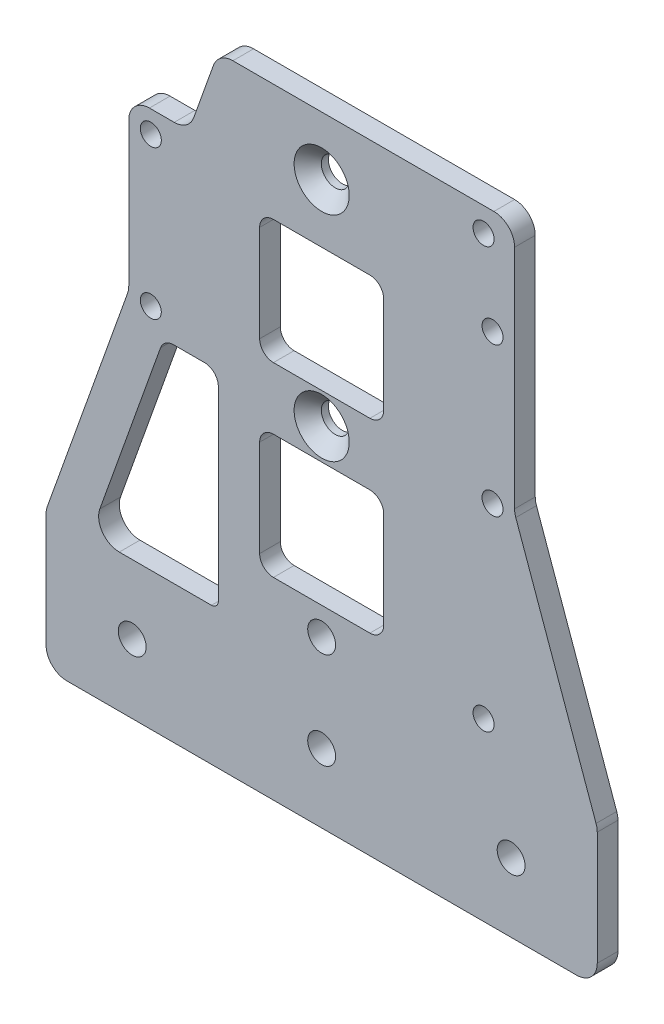
from build123d import *

# Parameters (mm, degrees)
EXTRUDE_1_DEPTH           = 1.5
SKETCH_2_W                = 18
SKETCH_2_H                = 18
CUT_EXTRUDE_1_DEPTH       = 3
FILLET_1_R                = 1
FILLET_2_R                = 2
FILLET_3_R                = 3
SKETCH_3_R                = 2.025
CUT_EXTRUDE_2_DEPTH       = 1
CUT_EXTRUDE_2_DEPTH_BACK  = 4
SKETCH_4_R                = 2.025
CUT_EXTRUDE_3_DEPTH       = 1
CUT_EXTRUDE_3_DEPTH_BACK  = 4
SKETCH_5_R                = 2.025
CUT_EXTRUDE_4_DEPTH       = 1
CUT_EXTRUDE_4_DEPTH_BACK  = 4
FILLET_4_R                = 3
EXTRUDE_2_DEPTH           = 3
FILLET_5_R                = 3
SKETCH_7_R                = 1.525
CUT_EXTRUDE_5_DEPTH       = 3
HOLE_WIZARD_1_D           = 4.05
HOLE_WIZARD_1_DEPTH       = 100
HOLE_WIZARD_1_CSINK_D     = 8
HOLE_WIZARD_1_CSINK_ANGLE = 90
EXTRUDE_3_DEPTH           = 3
FILLET_6_R                = 3
SKETCH_12_R               = 1.525
CUT_EXTRUDE_6_DEPTH       = 1
CUT_EXTRUDE_6_DEPTH_BACK  = 4
FILLET_7_R                = 2


with BuildPart() as part:
    # 草图1 → 凸台-拉伸1 (new body, symmetric)
    with BuildSketch(Plane.XY):
        Polygon((40, 0), (-40, 0), (-40, 20), (-15, 90), (15, 90), (40, 20), align=None)
    extrude(amount=EXTRUDE_1_DEPTH, both=True)

    # 草图2 → 切除-拉伸1 (cut)
    with BuildSketch(Plane.XY.offset(1.5)):
        Polygon((-15, 72.160717503), (-33.62882768, 20), (-15, 20), align=None)
        with Locations((0, 64)):
            Rectangle(SKETCH_2_W, SKETCH_2_H)
        with Locations((0, 37)):
            Rectangle(SKETCH_2_W, SKETCH_2_H)
    extrude(amount=-CUT_EXTRUDE_1_DEPTH, mode=Mode.SUBTRACT)

    # 圆角1
    fillet_1_edges = [part.edges().sort_by_distance(p)[0] for p in [
        (-15, 20, 0),
        (-15, 72.160717503, 0),
    ]]
    fillet(fillet_1_edges, radius=FILLET_1_R)

    # 圆角2
    fillet_2_edges = [part.edges().sort_by_distance(p)[0] for p in [
        (-9, 46, 0),
        (-9, 28, 0),
        (9, 28, 0),
        (9, 46, 0),
        (-9, 73, 0),
        (-9, 55, 0),
        (9, 55, 0),
        (9, 73, 0),
    ]]
    fillet(fillet_2_edges, radius=FILLET_2_R)

    # 圆角3
    fillet_3_edges = [part.edges().sort_by_distance(p)[0] for p in [
        (40, 0, 0),
        (-40, 0, 0),
        (-40, 20, 0),
        (-15, 90, 0),
        (15, 90, 0),
        (40, 20, 0),
    ]]
    fillet(fillet_3_edges, radius=FILLET_3_R)

    # 草图3 → 切除-拉伸2 (cut, two sides)
    with BuildSketch(Plane.XY.offset(1.5)) as cut_extrude_2_sk:
        with Locations((-27.5, 10)):
            Circle(SKETCH_3_R)
        with Locations((27.5, 10)):
            Circle(SKETCH_3_R)
    extrude(amount=CUT_EXTRUDE_2_DEPTH, mode=Mode.SUBTRACT)
    extrude(cut_extrude_2_sk.sketch, amount=-CUT_EXTRUDE_2_DEPTH_BACK, mode=Mode.SUBTRACT)

    # 草图4 → 切除-拉伸3 (cut, two sides)
    with BuildSketch(Plane.XY.offset(1.5)) as cut_extrude_3_sk:
        with Locations((0, 10)):
            Circle(SKETCH_4_R)
    extrude(amount=CUT_EXTRUDE_3_DEPTH, mode=Mode.SUBTRACT)
    extrude(cut_extrude_3_sk.sketch, amount=-CUT_EXTRUDE_3_DEPTH_BACK, mode=Mode.SUBTRACT)

    # 草图5 → 切除-拉伸4 (cut, two sides)
    with BuildSketch(Plane.XY.offset(1.5)) as cut_extrude_4_sk:
        with Locations((0, 24)):
            Circle(SKETCH_5_R)
        with Locations((0, 50.5)):
            Circle(SKETCH_5_R)
        with Locations((0, 81.5)):
            Circle(SKETCH_5_R)
    extrude(amount=CUT_EXTRUDE_4_DEPTH, mode=Mode.SUBTRACT)
    extrude(cut_extrude_4_sk.sketch, amount=-CUT_EXTRUDE_4_DEPTH_BACK, mode=Mode.SUBTRACT)

    # 圆角4
    fillet_4_edges = [part.edges().sort_by_distance(p)[0] for p in [
        (-33.62882768, 20, 0),
    ]]
    fillet(fillet_4_edges, radius=FILLET_4_R)

    # 草图6 → 凸台-拉伸2 (add)
    with BuildSketch(Plane(origin=(0, 0, -1.5), x_dir=(-1, 0, 0), z_dir=(0, 0, -1))):
        with BuildLine():
            Line((15, 66.387503754), (15, 50))
            Line((15, 50), (22.914541965, 50))
            Line((22.914541965, 50), (16.941741912, 66.723840151))
            ThreePointArc((16.941741912, 66.723840151), (15.82932767, 67.372831596), (15, 66.387503754))
        make_face()
        Polygon((-28, 78), (-28, 53.6), (-19.285714286, 78), align=None)
        Polygon((28, 78), (19.285714286, 78), (28, 53.6), align=None)
    extrude(amount=-EXTRUDE_2_DEPTH)

    # 圆角5
    fillet_5_edges = [part.edges().sort_by_distance(p)[0] for p in [
        (28, 53.6, 0),
        (-28, 78, 0),
        (19.285714286, 78, 0),
        (28, 78, 0),
        (-19.285714286, 78, 0),
        (-28, 53.6, 0),
    ]]
    fillet(fillet_5_edges, radius=FILLET_5_R)

    # 草图7 → 切除-拉伸5 (cut)
    with BuildSketch(Plane(origin=(0, 0, -1.5), x_dir=(-1, 0, 0), z_dir=(0, 0, -1))):
        with Locations((24.8, 74.8)):
            Circle(SKETCH_7_R)
        with Locations((24.8, 53.2)):
            Circle(SKETCH_7_R)
        with Locations((-24.8, 53.2)):
            Circle(SKETCH_7_R)
        with Locations((-24.8, 74.8)):
            Circle(SKETCH_7_R)
    extrude(amount=-CUT_EXTRUDE_5_DEPTH, mode=Mode.SUBTRACT)

    # 孔1
    with Locations(Plane.XY.offset(1.5)):
        with Locations((0, 81.5), (0, 50.5)):
            CounterSinkHole(HOLE_WIZARD_1_D / 2, HOLE_WIZARD_1_CSINK_D / 2, depth=HOLE_WIZARD_1_DEPTH, counter_sink_angle=HOLE_WIZARD_1_CSINK_ANGLE)

    # 草图11 → 凸台-拉伸3 (add)
    with BuildSketch(Plane.XY.offset(1.5)):
        with BuildLine():
            Line((12.885842411, 90), (28, 90))
            Line((28, 90), (28, 75))
            ThreePointArc((28, 75), (27.121320344, 77.121320344), (25, 78))
            Line((25, 78), (21.399871874, 78))
            ThreePointArc((21.399871874, 78), (19.671726564, 78.547753319), (18.57464614, 79.990990809))
            Line((18.57464614, 79.990990809), (15.711068146, 88.009009191))
            ThreePointArc((15.711068146, 88.009009191), (14.613987722, 89.452246681), (12.885842411, 90))
        make_face()
    extrude(amount=-EXTRUDE_3_DEPTH)

    # 圆角6
    fillet_6_edges = [part.edges().sort_by_distance(p)[0] for p in [
        (28, 90, 0),
    ]]
    fillet(fillet_6_edges, radius=FILLET_6_R)

    # 草图12 → 切除-拉伸6 (cut, two sides)
    with BuildSketch(Plane.XY.offset(1.5)) as cut_extrude_6_sk:
        with Locations((23.5, 86.5)):
            Circle(SKETCH_12_R)
        with Locations((23.5, 25.5)):
            Circle(SKETCH_12_R)
    extrude(amount=CUT_EXTRUDE_6_DEPTH, mode=Mode.SUBTRACT)
    extrude(cut_extrude_6_sk.sketch, amount=-CUT_EXTRUDE_6_DEPTH_BACK, mode=Mode.SUBTRACT)

    # 圆角7
    fillet_7_edges = [part.edges().sort_by_distance(p)[0] for p in [
        (-22.914541965, 50, 0),
        (-15, 50, 0),
    ]]
    fillet(fillet_7_edges, radius=FILLET_7_R)


solid = part.part
